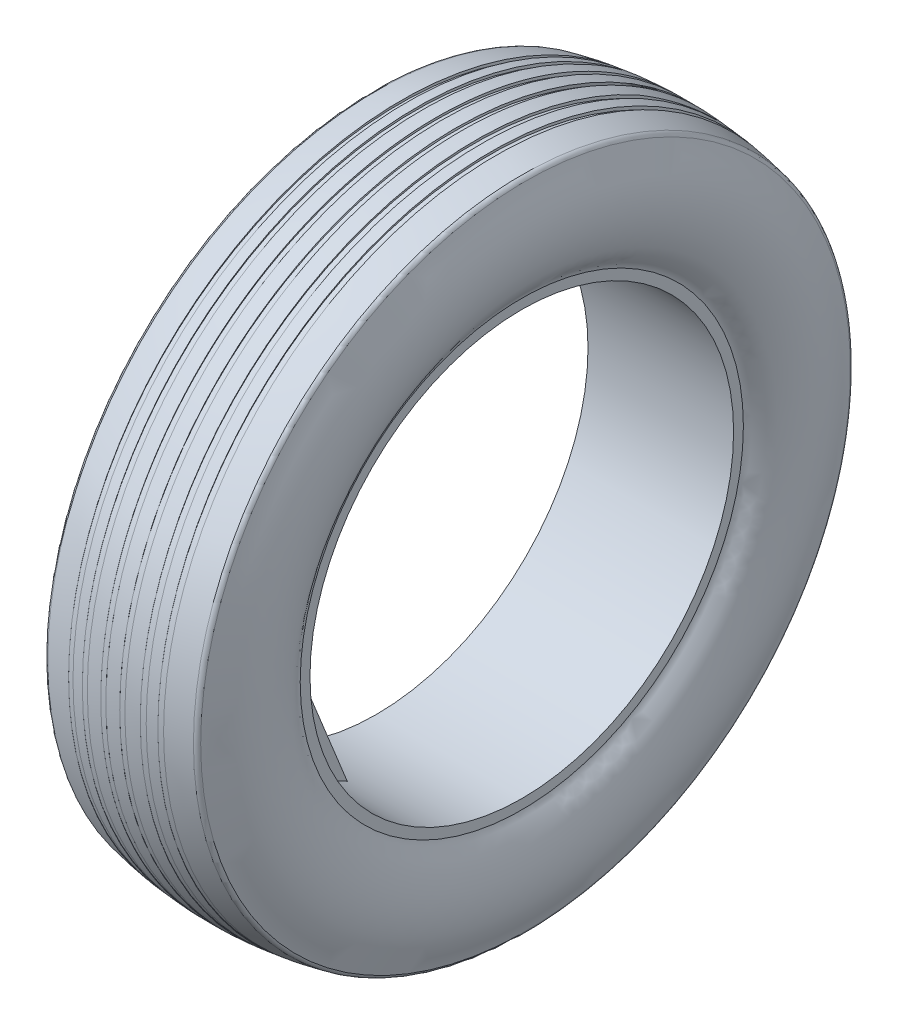
from build123d import *


with BuildPart() as part:
    # Sketch1 → Revolve4 (revolve)
    with BuildSketch(Plane.XY, mode=Mode.PRIVATE) as revolve4_sk:
        with BuildLine():
            Line((-7.920115187, 268.270115187), (-7.920115187, 256.54))
            Line((-7.920115187, 256.54), (166.670115187, 256.54))
            Line((166.670115187, 256.54), (166.670115187, 268.270115187))
            add(Edge.make_bspline(
                [(166.670115187, 268.270115187), (168.026887562, 273.933109882), (176.052266861, 280.87676414), (189.329801149, 311.629128898), (190.457315659, 348.930066681), (176.159896322, 378.942203265), (172.331934093, 388.396321064), (171.157927171, 392.094209105)],
                knots=[0, 0, 0, 0, 0.124300406, 0.22672345, 0.739099835, 0.879849246, 0.966039312, 0.966039312, 0.966039312, 0.966039312], degree=3))
            ThreePointArc((171.157927171, 392.094209105), (169.462568947, 394.792193421), (166.670115187, 396.32697708))
            ThreePointArc((166.670115187, 396.32697708), (166.459047785, 396.373107521), (166.247956006, 396.419126283))
            ThreePointArc((166.247956006, 396.419126283), (79.375000001, 405.766897978), (-7.497956004, 396.419126284))
            ThreePointArc((-7.497956004, 396.419126284), (-7.709047785, 396.373107521), (-7.920115189, 396.32697708))
            ThreePointArc((-7.920115189, 396.32697708), (-10.712568948, 394.792193421), (-12.407927171, 392.094209105))
            add(Edge.make_bspline(
                [(-7.920115187, 268.270115187), (-9.276887562, 273.933109882), (-17.302266861, 280.87676414), (-30.579801149, 311.629128898), (-31.707315659, 348.930066681), (-17.409896322, 378.942203265), (-13.581934093, 388.396321064), (-12.407927171, 392.094209105)],
                knots=[0, 0, 0, 0, 0.124300406, 0.22672345, 0.739099835, 0.879849246, 0.966039312, 0.966039312, 0.966039312, 0.966039312], degree=3))
        make_face()
    revolve(revolve4_sk.sketch.rotate(Axis((79.375, 2.54, 0), (1, 0, 0)), 90), axis=Axis((79.375, 2.54, 0), (1, 0, 0)))

    # Sketch4 → Cut-Revolve3 (revolve, cut)
    with BuildSketch(Plane.XY.offset(2.54), mode=Mode.PRIVATE) as cut_revolve3_sk:
        with BuildLine():
            ThreePointArc((136.335467816, 399.209439808), (133.29408958, 399.628875498), (130.249625144, 400.025289635))
            Line((130.249625144, 400.025289635), (130.249625144, 405.766897978))
            Line((130.249625144, 405.766897978), (136.335467816, 405.766897978))
            Line((136.335467816, 405.766897978), (136.335467816, 399.209439808))
        make_face()
        with BuildLine():
            ThreePointArc((117.677606201, 401.415239439), (114.402453264, 401.712369308), (111.124999998, 401.982948333))
            Line((111.124999998, 401.982948333), (111.124999998, 405.766897978))
            Line((111.124999998, 405.766897978), (117.677606201, 405.766897978))
            Line((117.677606201, 405.766897978), (117.677606201, 401.415239439))
        make_face()
        with BuildLine():
            ThreePointArc((93.874519422, 402.967781468), (90.770703369, 403.066862191), (87.666219997, 403.142188618))
            Line((87.666219997, 403.142188618), (87.666219997, 407.957841482))
            Line((87.666219997, 407.957841482), (93.874519422, 407.957841482))
            Line((93.874519422, 407.957841482), (93.874519422, 402.967781468))
        make_face()
        with BuildLine():
            Line((64.875480575, 407.957841482), (64.875480575, 402.967781468))
            ThreePointArc((64.875480575, 402.967781468), (67.979296628, 403.066862191), (71.08378, 403.142188618))
            Line((71.08378, 403.142188618), (71.08378, 407.957841482))
            Line((71.08378, 407.957841482), (64.875480575, 407.957841482))
        make_face()
        with BuildLine():
            Line((41.072393796, 401.415239439), (41.072393796, 405.766897978))
            Line((41.072393796, 405.766897978), (47.624999999, 405.766897978))
            Line((47.624999999, 405.766897978), (47.624999999, 401.982948333))
            ThreePointArc((47.624999999, 401.982948333), (44.347546733, 401.712369308), (41.072393796, 401.415239439))
        make_face()
        with BuildLine():
            Line((22.414532181, 399.209439808), (22.414532181, 405.766897978))
            Line((22.414532181, 405.766897978), (28.500374854, 405.766897978))
            Line((28.500374854, 405.766897978), (28.500374854, 400.025289635))
            ThreePointArc((28.500374854, 400.025289635), (25.455910417, 399.628875498), (22.414532181, 399.209439808))
        make_face()
    revolve(cut_revolve3_sk.sketch.rotate(Axis((-29.207029248, 2.54, 2.54), (1, 0, 0)), 90), axis=Axis((-29.207029248, 2.54, 2.54), (1, 0, 0)), mode=Mode.SUBTRACT)


solid = part.part
